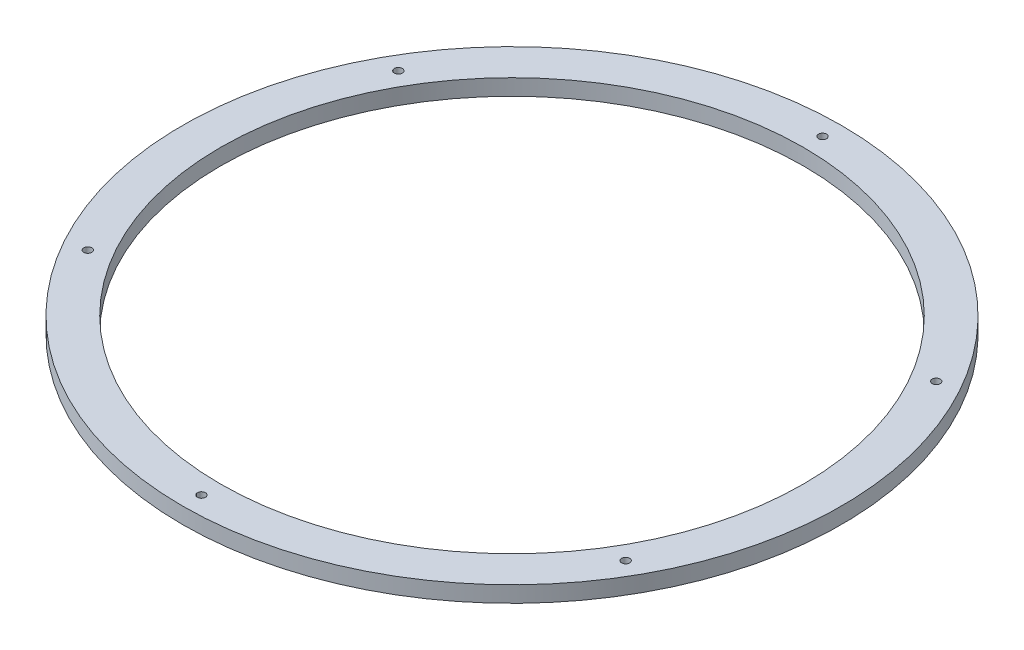
from build123d import *

# Parameters (mm, degrees)
SKETCH1_R           = 130
SKETCH1_R_2         = 1.5875
SKETCH1_R_3         = 115
BOSS_EXTRUDE1_DEPTH = 6.35


with BuildPart() as part:
    # Sketch1 → Boss-Extrude1 (new body)
    with BuildSketch(Plane(origin=(0, 0, 0), x_dir=(1, 0, 0), z_dir=(0, 1, 0))):
        Circle(SKETCH1_R)
        with Locations((-106.088111964, 61.25)):
            Circle(SKETCH1_R_2, mode=Mode.SUBTRACT)
        with Locations((-106.088111964, -61.25)):
            Circle(SKETCH1_R_2, mode=Mode.SUBTRACT)
        with Locations((0, -122.5)):
            Circle(SKETCH1_R_2, mode=Mode.SUBTRACT)
        with Locations((106.088111964, -61.25)):
            Circle(SKETCH1_R_2, mode=Mode.SUBTRACT)
        with Locations((106.088111964, 61.25)):
            Circle(SKETCH1_R_2, mode=Mode.SUBTRACT)
        with Locations((0, 122.5)):
            Circle(SKETCH1_R_2, mode=Mode.SUBTRACT)
        Circle(SKETCH1_R_3, mode=Mode.SUBTRACT)
    extrude(amount=BOSS_EXTRUDE1_DEPTH)


solid = part.part
